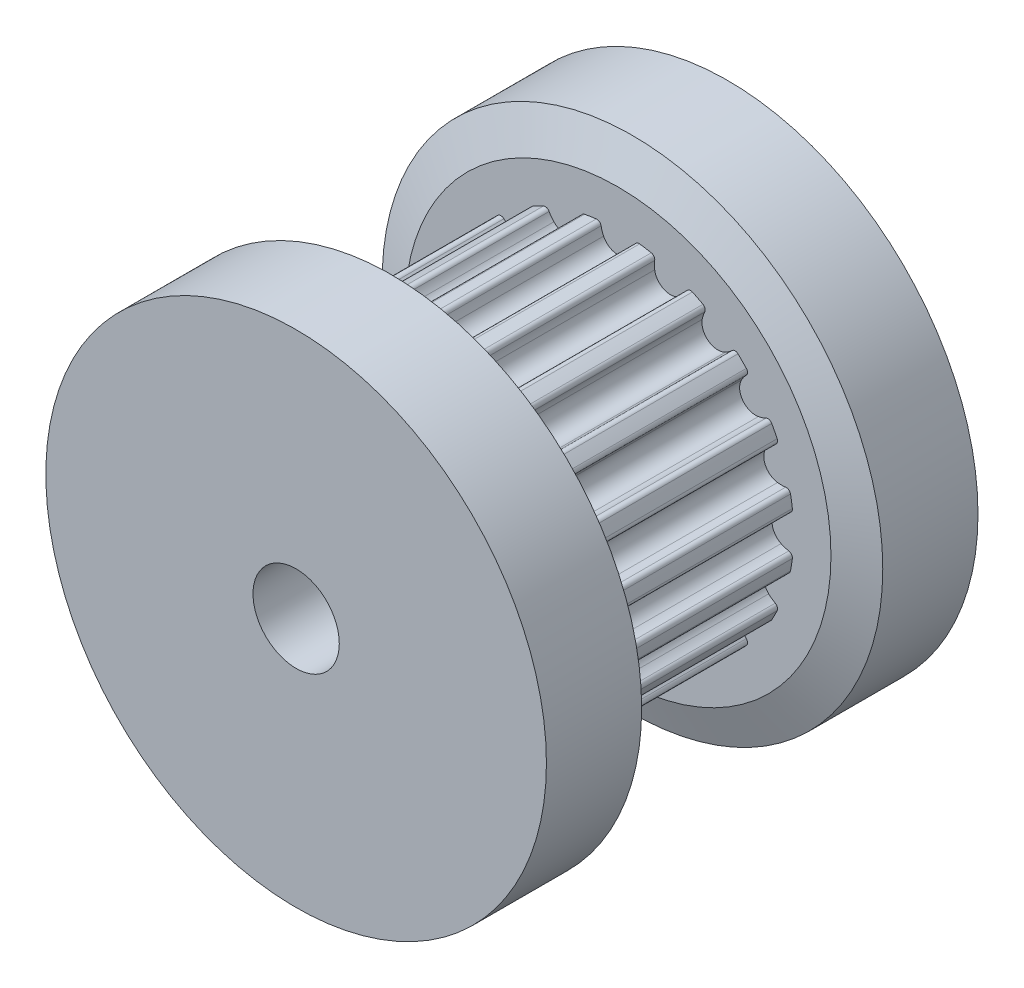
from build123d import *

# Parameters (mm, degrees)
CUT_EXTRUDE1_DEPTH = 3.685
CIRPATTERN1_COUNT  = 20
SKETCH6_R          = 1.5
CUT_EXTRUDE2_DEPTH = 16


with BuildPart() as part:
    # Sketch2 → Revolve1 (revolve)
    with BuildSketch(Plane(origin=(0, 0, 0), x_dir=(0, 0, -1), z_dir=(1, 0, 0))):
        Polygon((-3.685, 6.1085), (3.685, 6.1085), (3.685, 7.404), (4.19, 8.6995), (7.5, 8.6995), (7.5, 0), (-7.5, 0), (-7.5, 8.6995), (-4.19, 8.6995), (-3.685, 7.404), align=None)
    revolve(axis=Axis((0, 0, 7.5), (0, 0, -1)))

    # Sketch5 → Cut-Extrude1 (cut, symmetric)
    with BuildSketch(Plane.XY):
        with BuildLine():
            Line((2.840989707, 8.6995), (1.896292335, 5.806707124))
            ThreePointArc((1.896292335, 5.806707124), (1.330166224, 5.961914966), (0.751756185, 6.062065233))
            ThreePointArc((0.751756185, 6.062065233), (0.643911332, 6.033664451), (0.58547487, 5.93867868))
            ThreePointArc((0.58547487, 5.93867868), (0.551683777, 5.801420225), (0.498876404, 5.670297753))
            ThreePointArc((0.498876404, 5.670297753), (0, 5.3585), (-0.498876404, 5.670297753))
            ThreePointArc((-0.498876404, 5.670297753), (-0.551683777, 5.801420225), (-0.58547487, 5.93867868))
            ThreePointArc((-0.58547487, 5.93867868), (-0.643911332, 6.033664451), (-0.751756185, 6.062065233))
            ThreePointArc((-0.751756185, 6.062065233), (-1.330166224, 5.961914966), (-1.896292335, 5.806707124))
            Line((-1.896292335, 5.806707124), (-2.840989707, 8.6995))
            Line((-2.840989707, 8.6995), (2.840989707, 8.6995))
        make_face()
    cut_extrude1 = extrude(amount=CUT_EXTRUDE1_DEPTH, both=True, mode=Mode.SUBTRACT)

    # CirPattern1: Cut-Extrude1 ×20 about axis
    cirpattern1_axis = Axis((0, 0, 0), (0, 0, 1))
    for i in range(1, CIRPATTERN1_COUNT):
        add(cut_extrude1.rotate(cirpattern1_axis, i * 360 / CIRPATTERN1_COUNT), mode=Mode.SUBTRACT)

    # Sketch6 → Cut-Extrude2 (cut, through all)
    with BuildSketch(Plane.XY.offset(7.5)):
        Circle(SKETCH6_R)
    extrude(amount=-CUT_EXTRUDE2_DEPTH, mode=Mode.SUBTRACT)


solid = part.part
